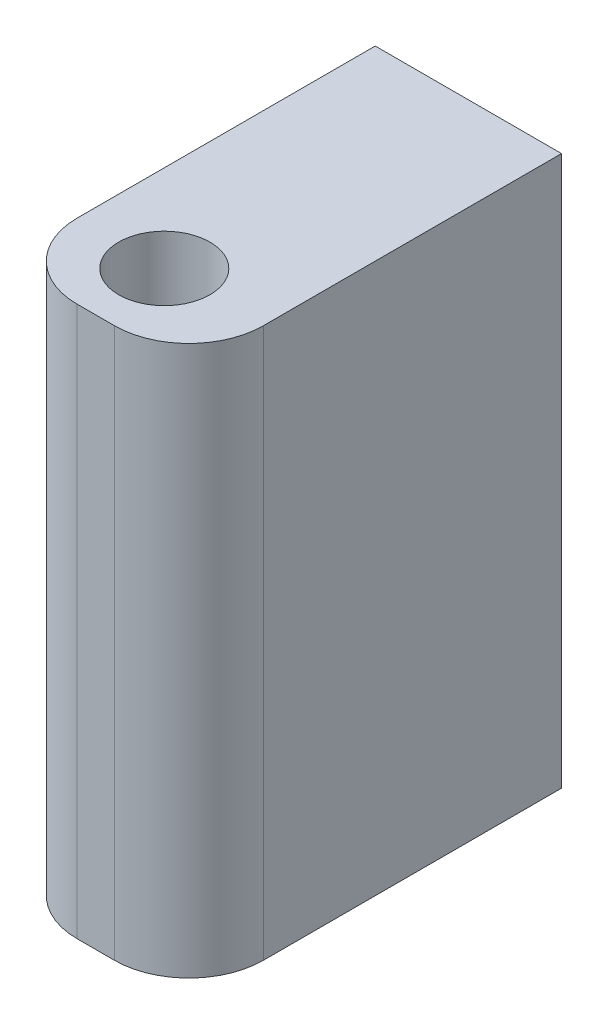
from build123d import *

# Parameters (mm, degrees)
SKETCH1_W      = 10
SKETCH1_H      = 29.5
EXTRUDE1_DEPTH = 20
SKETCH2_R      = 2.45
EXTRUDE2_DEPTH = 30.5
SKETCH4_R      = 1.95
EXTRUDE3_DEPTH = 11
FILLET1_R      = 4


with BuildPart() as part:
    # Sketch1 → Extrude1 (new body)
    with BuildSketch(Plane.XY):
        with Locations((0.322019203, 1.164845717)):
            Rectangle(SKETCH1_W, SKETCH1_H)
    extrude(amount=EXTRUDE1_DEPTH)

    # Sketch2 → Extrude2 (cut, through all)
    with BuildSketch(Plane(origin=(0, 15.914845717, 0), x_dir=(-1, 0, 0), z_dir=(0, 1, 0))):
        with Locations((0, 16)):
            Circle(SKETCH2_R)
    extrude(amount=-EXTRUDE2_DEPTH, mode=Mode.SUBTRACT)

    # Sketch4 → Extrude3 (cut)
    with BuildSketch(Plane.XY):
        with Locations((0, 7.914845717)):
            Circle(SKETCH4_R)
        with Locations((0, -7.085154283)):
            Circle(SKETCH4_R)
    extrude(amount=EXTRUDE3_DEPTH, mode=Mode.SUBTRACT)

    # Fillet1
    fillet1_edges = [part.edges().sort_by_distance(p)[0] for p in [
        (5.322019203, 1.164845717, 20),
        (-4.677980797, 1.164845717, 20),
    ]]
    fillet(fillet1_edges, radius=FILLET1_R)


solid = part.part
